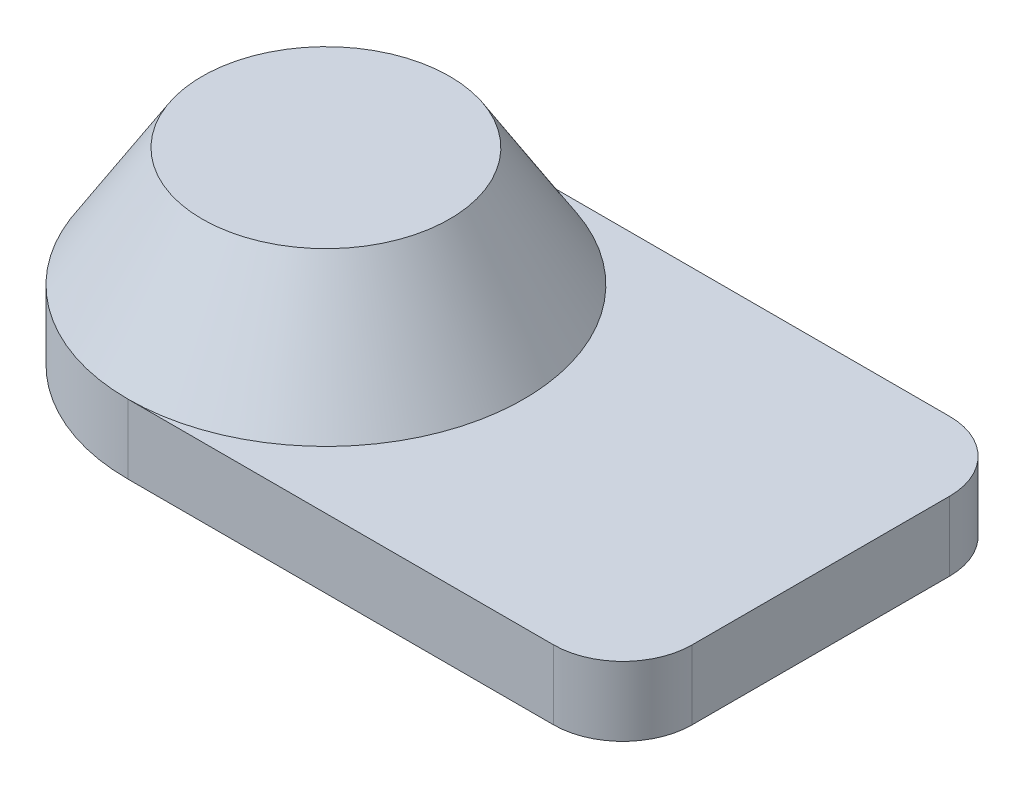
from build123d import *

# Parameters (mm, degrees)
BOSS_EXTRUDE1_DEPTH = 8.89
FILLET1_R           = 8.89
SKETCH4_R           = 25.4
SKETCH11_R          = 15.875


with BuildPart() as part:
    # Sketch1 → Boss-Extrude1 (new body)
    with BuildSketch(Plane(origin=(0, 0, 0), x_dir=(1, 0, 0), z_dir=(0, 1, 0))):
        with BuildLine():
            Line((0, 0), (63.5, 0))
            Line((63.5, 0), (63.5, 50.8))
            Line((63.5, 50.8), (0, 50.8))
            ThreePointArc((0, 50.8), (-25.4, 25.4), (0, 0))
        make_face()
    extrude(amount=BOSS_EXTRUDE1_DEPTH)

    # Fillet1
    fillet1_edges = [part.edges().sort_by_distance(p)[0] for p in [
        (63.5, 4.445, -50.8),
        (63.5, 4.445, 0),
    ]]
    fillet(fillet1_edges, radius=FILLET1_R)

    # Sketch4 → Loft2 section 0
    with BuildSketch(Plane(origin=(0, 8.89, 0), x_dir=(1, 0, 0), z_dir=(0, 1, 0))):
        with Locations((0, 25.4)):
            Circle(SKETCH4_R)
    # Sketch11 → Loft2 section 1
    with BuildSketch(Plane(origin=(0, 24.13, 0), x_dir=(1, 0, 0), z_dir=(0, 1, 0))):
        with Locations((0, 25.4)):
            Circle(SKETCH11_R)
    loft()


solid = part.part
